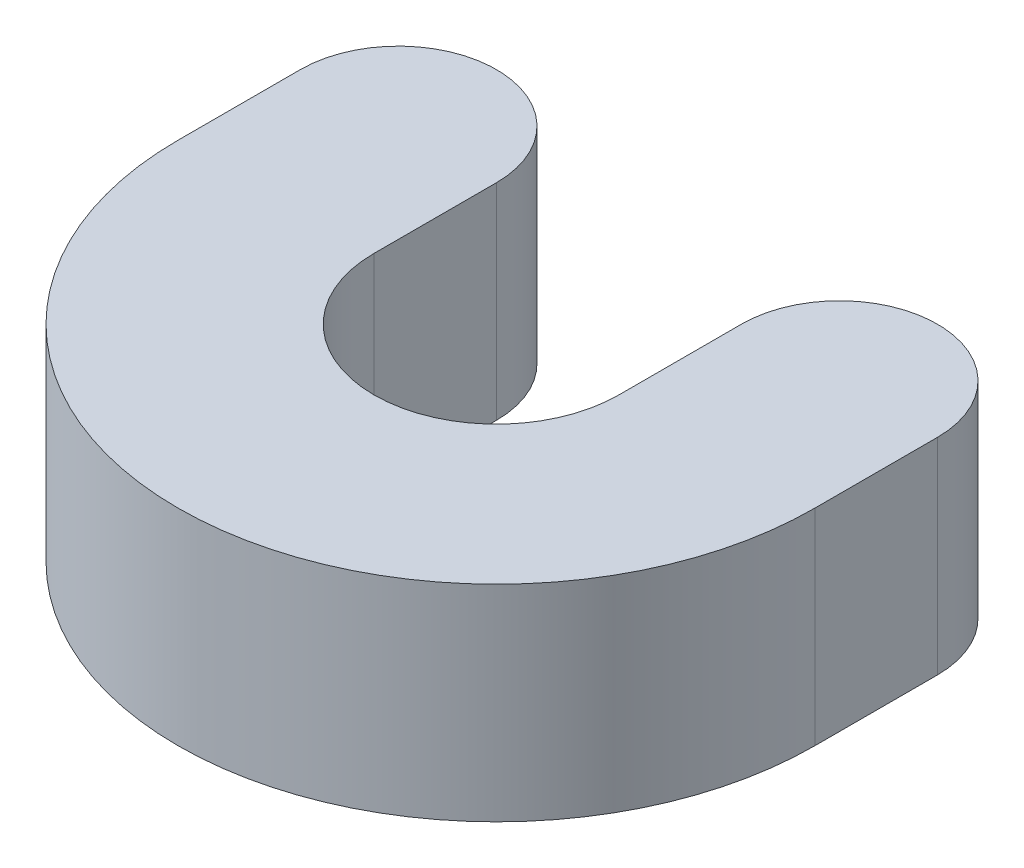
from build123d import *

# Parameters (mm, degrees)
EXTRUDE_1_DEPTH = 21


with BuildPart() as part:
    # Эскиз1 → Бобышка-Вытянуть1 (new body)
    with BuildSketch(Plane(origin=(0, 0, 0), x_dir=(1, 0, 0), z_dir=(0, 1, 0))):
        with BuildLine():
            Line((-32.5, 0), (-32.5, 12.5))
            ThreePointArc((-32.5, 12.5), (-22.5, 22.5), (-12.5, 12.5))
            Line((-12.5, 12.5), (-12.5, 0))
            ThreePointArc((-12.5, 0), (0, -12.5), (12.5, 0))
            Line((12.5, 0), (12.5, 12.5))
            ThreePointArc((12.5, 12.5), (22.5, 22.5), (32.5, 12.5))
            Line((32.5, 12.5), (32.5, 0))
            ThreePointArc((32.5, 0), (0, -32.5), (-32.5, 0))
        make_face()
    extrude(amount=EXTRUDE_1_DEPTH)


solid = part.part
